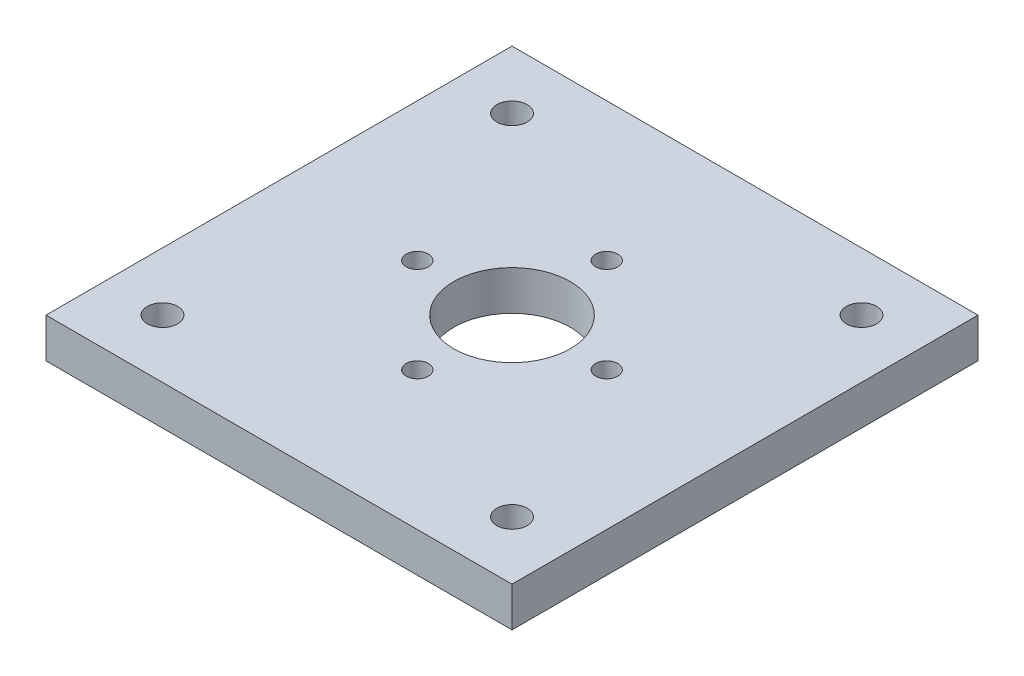
from build123d import *

# Parameters (mm, degrees)
SKETCH1_W           = 400
SKETCH1_H           = 400
SKETCH1_R           = 13
SKETCH1_R_2         = 50
SKETCH1_R_3         = 9.5
BOSS_EXTRUDE1_DEPTH = 34


with BuildPart() as part:
    # Sketch1 → Boss-Extrude1 (new body)
    with BuildSketch(Plane(origin=(0, 0, 0), x_dir=(1, 0, 0), z_dir=(0, 1, 0))):
        Rectangle(SKETCH1_W, SKETCH1_H)
        with Locations((-150, 150)):
            Circle(SKETCH1_R, mode=Mode.SUBTRACT)
        with Locations((-150, -150)):
            Circle(SKETCH1_R, mode=Mode.SUBTRACT)
        with Locations((150, -150)):
            Circle(SKETCH1_R, mode=Mode.SUBTRACT)
        with Locations((150, 150)):
            Circle(SKETCH1_R, mode=Mode.SUBTRACT)
        Circle(SKETCH1_R_2, mode=Mode.SUBTRACT)
        with Locations((0, 81.3)):
            Circle(SKETCH1_R_3, mode=Mode.SUBTRACT)
        with Locations((-81.3, 0)):
            Circle(SKETCH1_R_3, mode=Mode.SUBTRACT)
        with Locations((0, -81.3)):
            Circle(SKETCH1_R_3, mode=Mode.SUBTRACT)
        with Locations((81.3, 0)):
            Circle(SKETCH1_R_3, mode=Mode.SUBTRACT)
    extrude(amount=BOSS_EXTRUDE1_DEPTH)


solid = part.part
